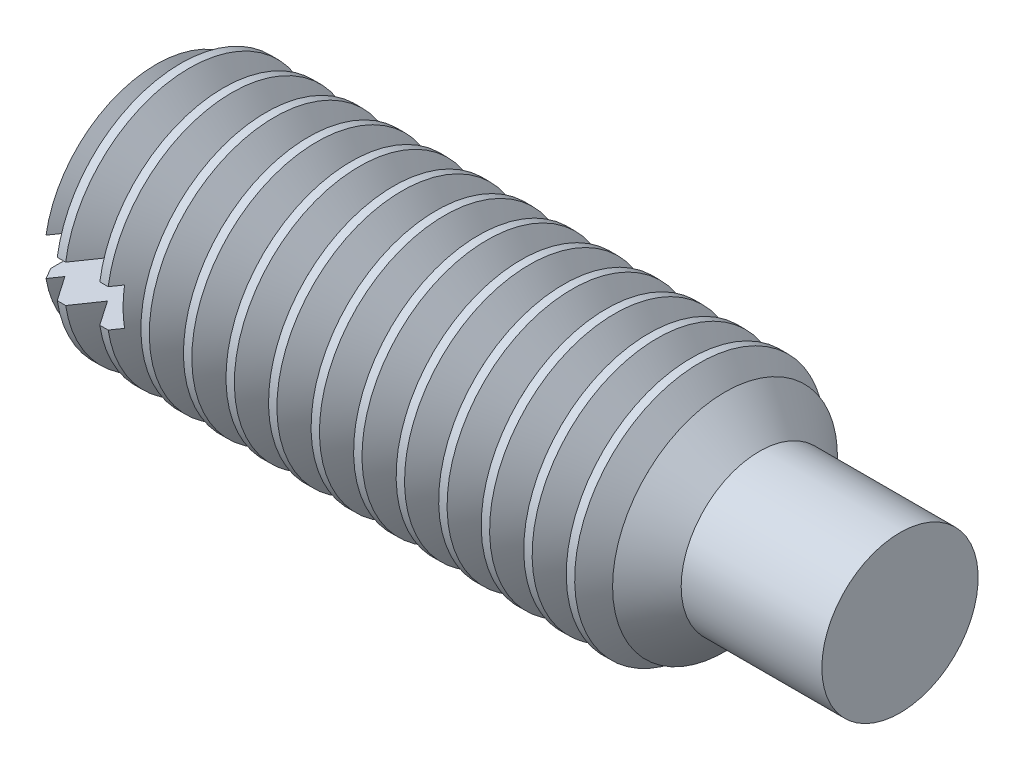
from build123d import *

# Parameters (mm, degrees)
SKETCH2_W       = 4
SKETCH2_H       = 0.6
SLOT_DEPTH      = 1.42
THDSCHPAT_COUNT = 14
THDSCHPAT_PITCH = 0.680345237


with BuildPart() as part:
    # BodySke → BaseBody (revolve)
    with BuildSketch(Plane.XY):
        Polygon((9.75, 1.25), (12, 1.25), (12, 0), (0, 0), (0, 1.61), (0.225166605, 2), (9, 2), align=None)
    revolve(axis=Axis((-12.7, 0, 0), (1, 0, 0)))

    # Sketch2 → Slot (cut)
    with BuildSketch(Plane(origin=(0, 0, 0), x_dir=(0, 0, -1), z_dir=(1, 0, 0))):
        Rectangle(SKETCH2_W, SKETCH2_H)
    extrude(amount=SLOT_DEPTH, mode=Mode.SUBTRACT)

    # ThdSchSke → ThreadSchematic (revolve, cut)
    with BuildSketch(Plane.XY):
        Polygon((0.225166605, -1.61), (-0.047914335, -2), (-0.047914335, -2.5), (0.498247545, -2.5), (0.498247545, -2), align=None)
    threadschematic = revolve(axis=Axis((-3.175, 0, 0), (1, 0, 0)), mode=Mode.SUBTRACT)

    # ThdSchPat: ThreadSchematic ×14
    with Locations(*[(i * THDSCHPAT_PITCH, 0, 0) for i in range(1, THDSCHPAT_COUNT)]):
        add(threadschematic, mode=Mode.SUBTRACT)


solid = part.part
